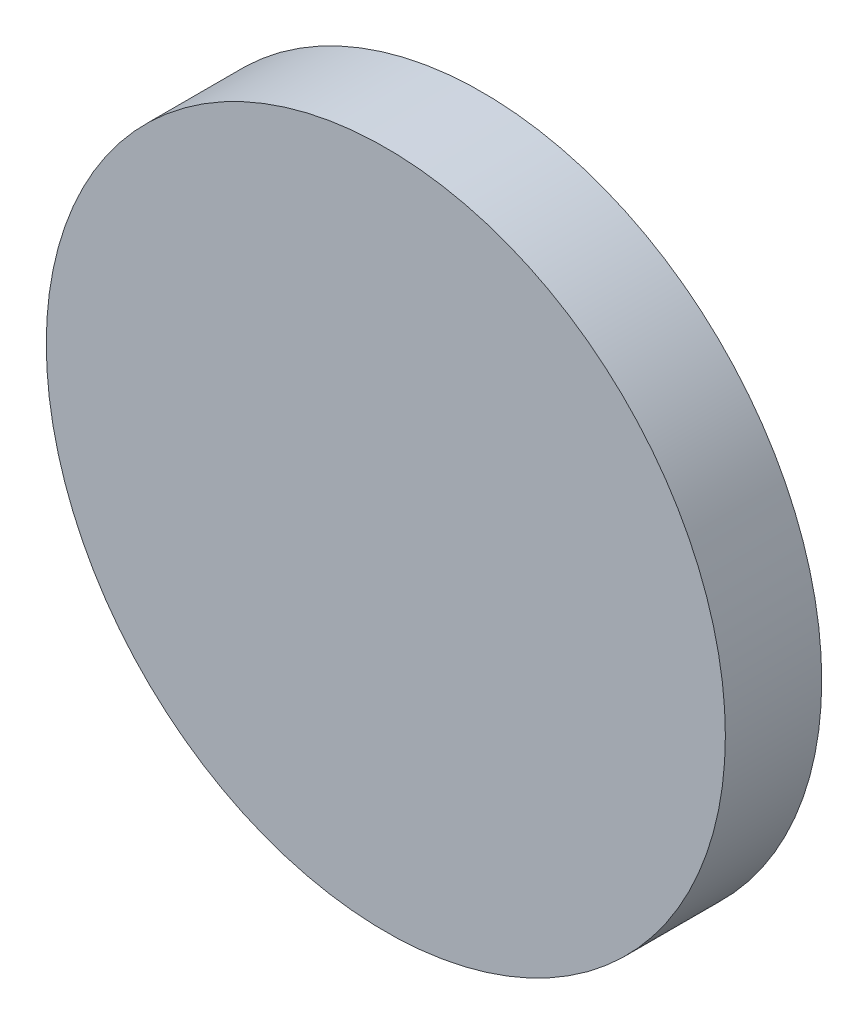
from build123d import *


with BuildPart() as part:
    # Sketch1 → Revolve1 (revolve)
    with BuildSketch(Plane(origin=(0, 0, 0), x_dir=(0, 0, -1), z_dir=(1, 0, 0))):
        Polygon((-2.596952363, 0), (-2.596952363, 136.52), (36.145188338, 136.52), (36.145188338, 133.52), (1.145188338, 133.52), (1.145188338, 98), (36.145188338, 98), (36.145188338, 95), (29.483104668, 95), (29.483104668, 96.257390859), (25.372970882, 96.257390859), (25.372970882, 95), (0.403047637, 95), (0.403047637, 0), align=None)
    revolve(axis=Axis((0, 0, 53.835453831), (0, 0, -1)))


solid = part.part
